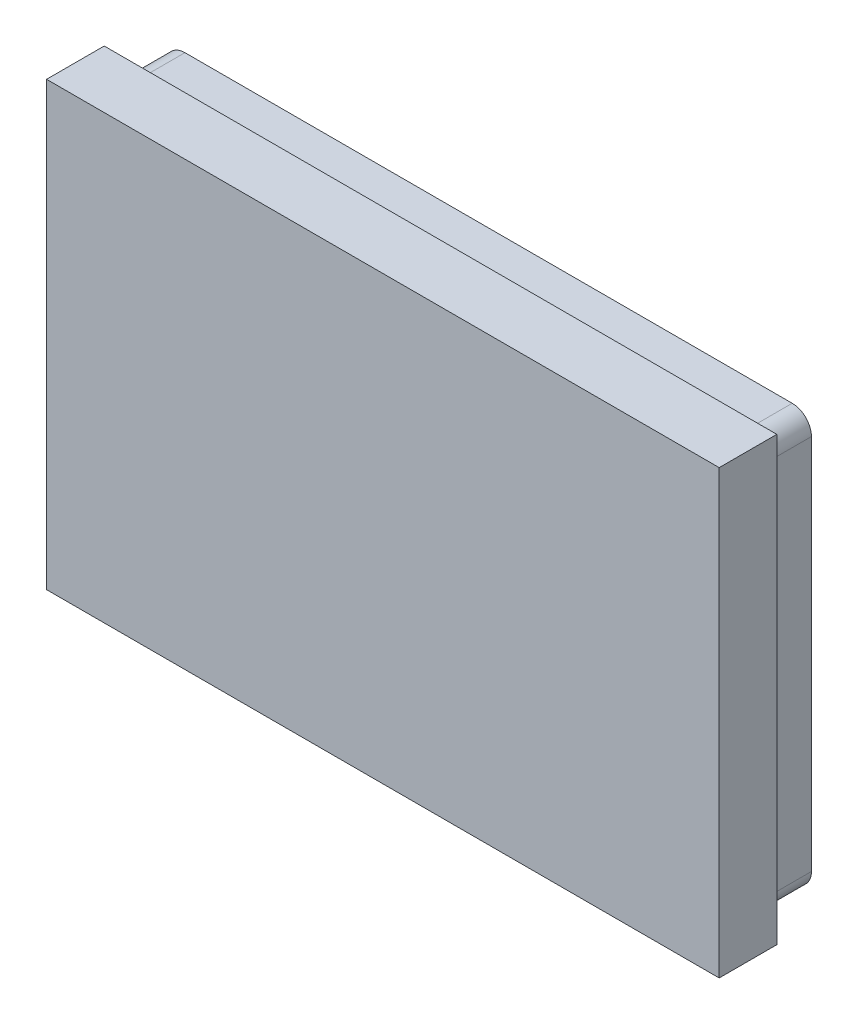
from build123d import *

# Parameters (mm, degrees)
ESQUISSE3_W        = 35
ESQUISSE3_H        = 23
BOSS_EXTRU_1_DEPTH = 3
BOSS_EXTRU_2_DEPTH = 2.5
BOSS_EXTRU_3_DEPTH = 2.5
BOSS_EXTRU_4_DEPTH = 2.5


with BuildPart() as part:
    # Esquisse3 → Boss.-Extru.1 (new body)
    with BuildSketch(Plane.XY):
        with Locations((17.5, 11.5)):
            Rectangle(ESQUISSE3_W, ESQUISSE3_H)
    extrude(amount=BOSS_EXTRU_1_DEPTH)

    # Esquisse4 → Boss.-Extru.2 (add)
    with BuildSketch(Plane(origin=(0, 0, 0), x_dir=(-1, 0, 0), z_dir=(0, 0, -1))):
        with BuildLine():
            Line((-33.3, 22.3), (-1.7, 22.3))
            ThreePointArc((-1.7, 22.3), (-0.992893219, 22.007106781), (-0.7, 21.3))
            Line((-0.7, 21.3), (-0.7, 1.7))
            ThreePointArc((-0.7, 1.7), (-0.992893219, 0.992893219), (-1.7, 0.7))
            Line((-1.7, 0.7), (-33.3, 0.7))
            ThreePointArc((-33.3, 0.7), (-34.007106781, 0.992893219), (-34.3, 1.7))
            Line((-34.3, 1.7), (-34.3, 21.3))
            ThreePointArc((-34.3, 21.3), (-34.007106781, 22.007106781), (-33.3, 22.3))
        make_face()
        with BuildLine():
            Line((-33, 21.7), (-2, 21.7))
            ThreePointArc((-2, 21.7), (-1.505025253, 21.494974747), (-1.3, 21))
            Line((-1.3, 21), (-1.3, 2))
            ThreePointArc((-1.3, 2), (-1.505025253, 1.505025253), (-2, 1.3))
            Line((-2, 1.3), (-33, 1.3))
            ThreePointArc((-33, 1.3), (-33.494974747, 1.505025253), (-33.7, 2))
            Line((-33.7, 2), (-33.7, 21))
            ThreePointArc((-33.7, 21), (-33.494974747, 21.494974747), (-33, 21.7))
        make_face(mode=Mode.SUBTRACT)
    extrude(amount=BOSS_EXTRU_2_DEPTH)

    # Esquisse5 → Boss.-Extru.3 (add)
    with BuildSketch(Plane(origin=(0, 0, 0), x_dir=(-1, 0, 0), z_dir=(0, 0, -1))):
        Polygon((-6.584721452, 15.316649388), (-5.479648989, 15.316649388), (-4.988254061, 16.909720041), (-4.809359134, 17.558497214), (-4.621406235, 16.893868591), (-4.092647177, 15.316649388), (-3.033996815, 15.316649388), (-2.780373626, 20.316649388), (-3.610310221, 20.316649388), (-3.707683409, 17.111259896), (-3.732592829, 16.2349012), (-3.9760258, 16.988977287), (-4.569322902, 18.794910258), (-5.161487757, 18.794910258), (-5.740065655, 16.854239968), (-5.926886308, 16.242826925), (-5.939341018, 17.022944678), (-6.040110945, 20.316649388), (-6.838344641, 20.316649388), align=None)
        Polygon((-7.671677974, 15.316649388), (-7.671677974, 20.316649388), (-10.715156235, 20.316649388), (-10.715156235, 19.519547939), (-8.61370696, 19.519547939), (-8.61370696, 18.287663881), (-10.642692467, 18.287663881), (-10.642692467, 17.490562432), (-8.61370696, 17.490562432), (-8.61370696, 16.113750838), (-10.715156235, 16.113750838), (-10.715156235, 15.316649388), align=None)
        Polygon((-18.83562725, 15.316649388), (-18.740518554, 18.15066207), (-18.70428667, 19.2817762), (-18.45745696, 18.560535258), (-17.887937032, 16.838388519), (-17.299168916, 16.838388519), (-16.80437725, 18.560535258), (-16.597176163, 19.2817762), (-16.567737757, 18.173306997), (-16.477158047, 15.316649388), (-15.678924351, 15.316649388), (-15.932547539, 20.316649388), (-16.994594641, 20.316649388), (-17.428245003, 18.876431997), (-17.63544609, 18.064611345), (-17.852837394, 18.830009896), (-18.329513119, 20.316649388), (-19.410808409, 20.316649388), (-19.664431597, 15.316649388), align=None)
        Polygon((-22.97285551, 15.316649388), (-22.694322902, 16.331142142), (-20.954060221, 16.331142142), (-20.668734134, 15.316649388), (-19.736895366, 15.316649388), (-21.220138119, 20.316649388), (-22.534676163, 20.316649388), (-24.012257684, 15.316649388), align=None)
        Polygon((-21.838344641, 19.459538881), (-21.180509496, 17.128243591), (-22.476931597, 17.128243591), align=None, mode=Mode.SUBTRACT)
        Polygon((-27.019504061, 15.316649388), (-25.497764931, 17.733995403), (-25.497764931, 15.316649388), (-24.555735945, 15.316649388), (-24.555735945, 20.316649388), (-25.497764931, 20.316649388), (-25.497764931, 17.995544316), (-27.044413481, 20.316649388), (-28.178924351, 20.316649388), (-26.430735945, 17.915154823), (-28.234404423, 15.316649388), align=None)
        Polygon((-29.048489568, 15.316649388), (-29.048489568, 20.316649388), (-32.091967829, 20.316649388), (-32.091967829, 19.519547939), (-29.990518554, 19.519547939), (-29.990518554, 18.287663881), (-32.019504061, 18.287663881), (-32.019504061, 17.490562432), (-29.990518554, 17.490562432), (-29.990518554, 16.113750838), (-32.091967829, 16.113750838), (-32.091967829, 15.316649388), align=None)
    extrude(amount=BOSS_EXTRU_3_DEPTH)

    # Esquisse7 → Boss.-Extru.4 (add)
    with BuildSketch(Plane(origin=(0, 0, 0), x_dir=(-1, 0, 0), z_dir=(0, 0, -1))):
        with BuildLine():
            add(Edge.make_bspline(
                [(-8.817747763, 9.314224142), (-8.814780119, 9.205506733), (-8.808942438, 8.991647656), (-8.762927378, 8.677420866), (-8.690845179, 8.375371259), (-8.58588107, 8.087519577), (-8.453474945, 7.814742721), (-8.289699633, 7.56056938), (-8.098821055, 7.324302512), (-7.877184803, 7.109473557), (-7.627410891, 6.915701806), (-7.347369711, 6.746245514), (-7.039802704, 6.597385002), (-6.70353827, 6.47307545), (-6.339922496, 6.371040526), (-5.947059319, 6.30536668), (-5.527582272, 6.257959268), (-5.238170675, 6.254172069), (-5.089001447, 6.252220061)],
                knots=[0, 0, 0, 0, 0.000326028, 0.000641332, 0.000950735, 0.001256132, 0.001558628, 0.001858505, 0.002161265, 0.002467876, 0.002782402, 0.003107603, 0.003448034, 0.003805964, 0.004181842, 0.004579127, 0.004999629, 0.005446896, 0.005446896, 0.005446896, 0.005446896], degree=3))
            Line((-5.089001447, 6.252220061), (-4.214143138, 6.252220061))
            Line((-4.214143138, 6.252220061), (-4.214143138, 3.519733097))
            Line((-4.214143138, 3.519733097), (-2.481769526, 3.519733097))
            Line((-2.481769526, 3.519733097), (-2.481769526, 12.019733097))
            Line((-2.481769526, 12.019733097), (-5.158373471, 12.019733097))
            add(Edge.make_bspline(
                [(-5.158373471, 12.019733097), (-5.301678682, 12.01747456), (-5.580327474, 12.013082963), (-5.985818438, 11.980271354), (-6.365985176, 11.925810589), (-6.71965664, 11.845630839), (-7.0488036, 11.749471573), (-7.349709983, 11.627715027), (-7.624270715, 11.486399568), (-7.872366824, 11.325250737), (-8.091346919, 11.140475141), (-8.283906388, 10.937686688), (-8.44742762, 10.713425051), (-8.582248531, 10.469927813), (-8.689602869, 10.207632387), (-8.764238727, 9.925937057), (-8.808902863, 9.62590226), (-8.814753892, 9.419722686), (-8.817747763, 9.314224142)],
                knots=[0, 0, 0, 0, 0.000429877, 0.000835871, 0.001219581, 0.001580964, 0.001922978, 0.002247179, 0.002553141, 0.002848167, 0.003132647, 0.003410736, 0.003685163, 0.003962919, 0.004243825, 0.00453317, 0.004835126, 0.00515153, 0.00515153, 0.00515153, 0.00515153], degree=3))
        make_face()
        with BuildLine():
            add(Edge.make_bspline(
                [(-7.016002127, 9.204385103), (-7.014435945, 9.259690989), (-7.011382707, 9.367508671), (-6.989960867, 9.525799552), (-6.953383113, 9.675475656), (-6.903332905, 9.818012799), (-6.837430434, 9.950917504), (-6.758079256, 10.075580637), (-6.663423931, 10.190105607), (-6.551987026, 10.291923723), (-6.42800876, 10.386310201), (-6.28665871, 10.46592213), (-6.130858503, 10.536414431), (-5.958863362, 10.593234882), (-5.771532984, 10.639800715), (-5.567826504, 10.671957108), (-5.34760432, 10.691383553), (-5.195029299, 10.69307848), (-5.115979456, 10.693956629)],
                knots=[0, 0, 0, 0, 0.000165901, 0.000323421, 0.000478122, 0.000627449, 0.000775678, 0.000922143, 0.001069932, 0.001219917, 0.001374077, 0.001536369, 0.001705419, 0.001886403, 0.002078958, 0.002283928, 0.00250445, 0.002741541, 0.002741541, 0.002741541, 0.002741541], degree=3))
            Line((-5.115979456, 10.693956629), (-4.214143138, 10.693956629))
            Line((-4.214143138, 10.693956629), (-4.214143138, 7.577996529))
            Line((-4.214143138, 7.577996529), (-5.171862476, 7.577996529))
            add(Edge.make_bspline(
                [(-5.171862476, 7.577996529), (-5.244506876, 7.579483738), (-5.384979631, 7.58235956), (-5.58910513, 7.604284199), (-5.780263267, 7.637724065), (-5.958288586, 7.687990995), (-6.122816971, 7.752500231), (-6.275870951, 7.826136733), (-6.413257292, 7.916184934), (-6.538324753, 8.016515748), (-6.647668785, 8.130894108), (-6.744536776, 8.254796664), (-6.828792656, 8.388421912), (-6.89535982, 8.534098658), (-6.950122838, 8.688643616), (-6.987943508, 8.852849454), (-7.011898418, 9.025751459), (-7.014613164, 9.143923805), (-7.016002127, 9.204385103)],
                knots=[0, 0, 0, 0, 0.000217887, 0.00042133, 0.000615231, 0.000799458, 0.000975164, 0.001144937, 0.00130796, 0.001466864, 0.001624949, 0.001781452, 0.001938121, 0.002097608, 0.002260938, 0.002429206, 0.002602261, 0.002783563, 0.002783563, 0.002783563, 0.002783563], degree=3))
        make_face(mode=Mode.SUBTRACT)
        with BuildLine():
            add(Edge.make_bspline(
                [(-17.040259665, 7.80538261), (-17.037584538, 7.618935783), (-17.032414822, 7.258625051), (-16.974385002, 6.738245696), (-16.886724091, 6.256581468), (-16.758540243, 5.815178867), (-16.600643458, 5.412817311), (-16.415096781, 5.046831071), (-16.201349174, 4.718477923), (-15.961086606, 4.426593959), (-15.695039437, 4.172809855), (-15.407169257, 3.953463691), (-15.095708585, 3.771811546), (-14.765753922, 3.622906205), (-14.418865664, 3.510359585), (-14.059526482, 3.429647053), (-13.688837718, 3.377004353), (-13.436948079, 3.371971687), (-13.309586348, 3.369427044)],
                knots=[0, 0, 0, 0, 0.000559099, 0.001080466, 0.001568762, 0.002026156, 0.002456995, 0.00286377, 0.003255008, 0.003630036, 0.003995303, 0.004355657, 0.00471325, 0.005074633, 0.005439651, 0.005805218, 0.006178579, 0.006560436, 0.006560436, 0.006560436, 0.006560436], degree=3))
            add(Edge.make_bspline(
                [(-13.309586348, 3.369427044), (-13.16360512, 3.372521153), (-12.880295652, 3.378525969), (-12.469962605, 3.431557732), (-12.086980341, 3.51670416), (-11.732900306, 3.641527061), (-11.403737887, 3.796399293), (-11.105667052, 3.991941182), (-10.832443595, 4.218084273), (-10.591171362, 4.482573821), (-10.378923985, 4.779776843), (-10.192634174, 5.107431906), (-10.037116766, 5.467679138), (-9.910429596, 5.859597989), (-9.810505499, 6.282314671), (-9.740424964, 6.736537172), (-9.697345634, 7.221946946), (-9.692946735, 7.556063242), (-9.690679071, 7.728302582)],
                knots=[0, 0, 0, 0, 0.000437773, 0.000849597, 0.001238994, 0.001612579, 0.001973715, 0.00232755, 0.002679136, 0.003035089, 0.00339821, 0.003772748, 0.004163682, 0.004573187, 0.005006933, 0.005465357, 0.005950888, 0.006467501, 0.006467501, 0.006467501, 0.006467501], degree=3))
            add(Edge.make_bspline(
                [(-9.690679071, 7.728302582), (-9.693305502, 7.914757071), (-9.698381111, 8.27508261), (-9.756982328, 8.794613096), (-9.842188292, 9.275903593), (-9.969898581, 9.717106095), (-10.131366906, 10.118809705), (-10.314540856, 10.48630835), (-10.530318808, 10.813465079), (-10.769765156, 11.105202623), (-11.035878268, 11.359013281), (-11.32349403, 11.577666652), (-11.633615092, 11.760511795), (-11.963317842, 11.908727359), (-12.310699206, 12.021749858), (-12.670832876, 12.101845921), (-13.042090109, 12.15479955), (-13.293986994, 12.159801856), (-13.421352388, 12.162331147)],
                knots=[0, 0, 0, 0, 0.000559099, 0.001080466, 0.001566513, 0.002023907, 0.002455457, 0.002863949, 0.003253575, 0.003628603, 0.00399387, 0.004354224, 0.004710157, 0.00507154, 0.005436558, 0.005804004, 0.006177365, 0.006559222, 0.006559222, 0.006559222, 0.006559222], degree=3))
            add(Edge.make_bspline(
                [(-13.421352388, 12.162331147), (-13.567327295, 12.159219208), (-13.850624495, 12.15317979), (-14.261043809, 12.100391365), (-14.643517814, 12.014437932), (-14.998469166, 11.892711215), (-15.327047013, 11.737012096), (-15.625233583, 11.542478013), (-15.896046342, 11.314976981), (-16.138348599, 11.052476929), (-16.352229181, 10.756404128), (-16.537686793, 10.428532687), (-16.694326611, 10.069443944), (-16.820397733, 9.677896263), (-16.920682307, 9.254630946), (-16.990461028, 8.799054665), (-17.033546647, 8.312378557), (-17.037979082, 7.977622048), (-17.040259665, 7.80538261)],
                knots=[0, 0, 0, 0, 0.000437773, 0.000849597, 0.001238994, 0.001611947, 0.001973084, 0.002326918, 0.002677028, 0.003031565, 0.003395814, 0.003770351, 0.00415952, 0.004569024, 0.005002771, 0.005463098, 0.005950549, 0.006467162, 0.006467162, 0.006467162, 0.006467162], degree=3))
        make_face()
        with BuildLine():
            add(Edge.make_bspline(
                [(-15.223098023, 7.728302582), (-15.221315644, 7.850361154), (-15.217870558, 8.08628302), (-15.200096505, 8.427923105), (-15.164262832, 8.744714325), (-15.119879264, 9.038582185), (-15.058535123, 9.308435145), (-14.982866981, 9.554102499), (-14.897917442, 9.777310698), (-14.795099563, 9.975764267), (-14.6772946, 10.150894816), (-14.542653832, 10.303988807), (-14.390059048, 10.434132862), (-14.217941569, 10.538923627), (-14.029128736, 10.620368929), (-13.823009152, 10.677690957), (-13.599847551, 10.712952296), (-13.445254587, 10.716946325), (-13.365469368, 10.719007638)],
                knots=[0, 0, 0, 0, 0.000366211, 0.000707834, 0.00102576, 0.001322293, 0.001599031, 0.001855039, 0.002093006, 0.002314511, 0.002524023, 0.002724699, 0.002924309, 0.003123267, 0.003326955, 0.00353924, 0.003763544, 0.004002771, 0.004002771, 0.004002771, 0.004002771], degree=3))
            add(Edge.make_bspline(
                [(-13.365469368, 10.719007638), (-13.285648632, 10.717178397), (-13.131519019, 10.713646229), (-12.909789818, 10.675508973), (-12.704968321, 10.6170503), (-12.519060446, 10.530758441), (-12.348803373, 10.424586885), (-12.197111225, 10.292579499), (-12.059352697, 10.139584616), (-11.938156509, 9.962812375), (-11.832592343, 9.765369236), (-11.740887432, 9.546896578), (-11.667227578, 9.306469078), (-11.608133997, 9.044790543), (-11.56144463, 8.763666101), (-11.533230785, 8.461609273), (-11.509608832, 8.140403708), (-11.508441009, 7.919126), (-11.507840712, 7.80538261)],
                knots=[0, 0, 0, 0, 0.000239228, 0.000461936, 0.000672905, 0.000876402, 0.001074743, 0.001272887, 0.001477567, 0.001690847, 0.001914154, 0.002148212, 0.002400538, 0.002667454, 0.002952572, 0.003254761, 0.003577267, 0.003918396, 0.003918396, 0.003918396, 0.003918396], degree=3))
            add(Edge.make_bspline(
                [(-11.507840712, 7.80538261), (-11.509597052, 7.683319645), (-11.512991807, 7.447389289), (-11.531115855, 7.105808245), (-11.565764736, 6.788713618), (-11.614176874, 6.495564476), (-11.672232161, 6.224497425), (-11.747282914, 5.977735708), (-11.83537565, 5.754864704), (-11.937713784, 5.556005478), (-12.055551321, 5.380290091), (-12.191561595, 5.228275846), (-12.345321171, 5.099648044), (-12.516776993, 4.994639376), (-12.705155037, 4.913737727), (-12.910401597, 4.855669564), (-13.132400519, 4.82089747), (-13.286334725, 4.816789423), (-13.365469368, 4.814677554)],
                knots=[0, 0, 0, 0, 0.000366211, 0.000707834, 0.00102576, 0.0013226, 0.001598914, 0.001856765, 0.002095441, 0.002316946, 0.002526458, 0.002728416, 0.002926785, 0.003125743, 0.003329431, 0.003539863, 0.003764166, 0.004001469, 0.004001469, 0.004001469, 0.004001469], degree=3))
            add(Edge.make_bspline(
                [(-13.365469368, 4.814677554), (-13.445272133, 4.816575966), (-13.60000119, 4.820256784), (-13.82258944, 4.857698132), (-14.027253925, 4.917347716), (-14.215011639, 5.000104458), (-14.383509107, 5.110163376), (-14.537744738, 5.240226621), (-14.674772664, 5.393530589), (-14.795357985, 5.569267452), (-14.898304102, 5.76742949), (-14.989882136, 5.98537644), (-15.06150638, 6.226209112), (-15.121145686, 6.486913365), (-15.167053587, 6.768863472), (-15.198327951, 7.071298328), (-15.221146298, 7.393301453), (-15.222435391, 7.614565972), (-15.223098023, 7.728302582)],
                knots=[0, 0, 0, 0, 0.000239228, 0.000463837, 0.000674806, 0.000877508, 0.001076885, 0.001276495, 0.001481174, 0.001691774, 0.001914173, 0.002150009, 0.002399925, 0.002666841, 0.002951959, 0.003256266, 0.003578773, 0.003919901, 0.003919901, 0.003919901, 0.003919901], degree=3))
        make_face(mode=Mode.SUBTRACT)
        with BuildLine():
            Line((-22.830896709, 3.519733097), (-21.545587255, 6.252220061))
            add(Edge.make_bspline(
                [(-21.545587255, 6.252220061), (-21.513934265, 6.314277417), (-21.452411052, 6.434896919), (-21.33254639, 6.595350636), (-21.194574264, 6.731466314), (-21.039463401, 6.844203994), (-20.868286444, 6.931583366), (-20.682374541, 6.992872768), (-20.482982651, 7.03329977), (-20.344628898, 7.036696566), (-20.273766806, 7.038436339)],
                knots=[0, 0, 0, 0, 0.000208695, 0.000405636, 0.000597767, 0.00078818, 0.000978641, 0.001171813, 0.001374001, 0.001586286, 0.001586286, 0.001586286, 0.001586286], degree=3))
            Line((-20.273766806, 7.038436339), (-19.94424969, 7.038436339))
            Line((-19.94424969, 7.038436339), (-19.94424969, 3.519733097))
            Line((-19.94424969, 3.519733097), (-18.227292084, 3.519733097))
            Line((-18.227292084, 3.519733097), (-18.227292084, 12.019733097))
            Line((-18.227292084, 12.019733097), (-20.888480023, 12.019733097))
            add(Edge.make_bspline(
                [(-20.888480023, 12.019733097), (-21.011212101, 12.018393777), (-21.251121308, 12.015775756), (-21.602060889, 11.991266783), (-21.936261907, 11.956706017), (-22.2519361, 11.901833561), (-22.549391217, 11.835220218), (-22.82397996, 11.744070893), (-23.075972357, 11.634463613), (-23.305479351, 11.505176254), (-23.511280403, 11.354531412), (-23.692235991, 11.181695166), (-23.847534206, 10.987169578), (-23.978320677, 10.771333007), (-24.080493295, 10.531239484), (-24.156705614, 10.267613332), (-24.197492797, 9.977733746), (-24.203605619, 9.776821708), (-24.206775194, 9.672646269)],
                knots=[0, 0, 0, 0, 0.000368138, 0.000719613, 0.001054989, 0.00137559, 0.001680349, 0.001968582, 0.002242114, 0.002503598, 0.002757202, 0.003005254, 0.00325203, 0.003501872, 0.003759961, 0.004032596, 0.004322832, 0.004635386, 0.004635386, 0.004635386, 0.004635386], degree=3))
            add(Edge.make_bspline(
                [(-24.206775194, 9.672646269), (-24.204865831, 9.596769673), (-24.201147766, 9.449016659), (-24.173935733, 9.233424062), (-24.128385117, 9.030424984), (-24.062263075, 8.840994017), (-23.980294595, 8.664946024), (-23.886914648, 8.499181451), (-23.773275226, 8.349220437), (-23.648551303, 8.209445111), (-23.508328728, 8.084631493), (-23.357623403, 7.969024596), (-23.191483435, 7.869694185), (-23.013606453, 7.783579536), (-22.827159423, 7.707893393), (-22.630696758, 7.647322234), (-22.427318611, 7.593676949), (-22.287073073, 7.570461288), (-22.216183492, 7.558726522)],
                knots=[0, 0, 0, 0, 0.00022759, 0.000443182, 0.000650735, 0.000850624, 0.001043757, 0.001232819, 0.001420125, 0.001607044, 0.001793963, 0.001982425, 0.002176087, 0.002373442, 0.002574903, 0.002779066, 0.00298985, 0.003205295, 0.003205295, 0.003205295, 0.003205295], degree=3))
            add(Edge.make_bspline(
                [(-22.216183492, 7.558726522), (-22.271448896, 7.545254307), (-22.383530679, 7.517931791), (-22.54205523, 7.439613282), (-22.694603095, 7.336708666), (-22.837659294, 7.201634671), (-22.979875483, 7.040384493), (-23.117320234, 6.844818009), (-23.25892289, 6.620075651), (-23.344724008, 6.454621311), (-23.389726906, 6.367840102)],
                knots=[0, 0, 0, 0, 0.000170199, 0.000345174, 0.000526896, 0.000720557, 0.000933558, 0.00117101, 0.001436754, 0.001729886, 0.001729886, 0.001729886, 0.001729886], degree=3))
            Line((-23.389726906, 6.367840102), (-24.848466421, 3.519733097))
            Line((-24.848466421, 3.519733097), (-22.830896709, 3.519733097))
        make_face()
        with BuildLine():
            add(Edge.make_bspline(
                [(-22.403102558, 9.516559213), (-22.402414452, 9.566755684), (-22.401075562, 9.664426156), (-22.378750236, 9.80437032), (-22.346608527, 9.933981262), (-22.299824896, 10.052405416), (-22.240967686, 10.160998894), (-22.165636657, 10.256747628), (-22.078750009, 10.342380951), (-21.976859885, 10.415951993), (-21.862287514, 10.478853263), (-21.735534414, 10.535597202), (-21.595506716, 10.582965534), (-21.441577183, 10.621953183), (-21.274493114, 10.649554103), (-21.094450247, 10.670666468), (-20.901548704, 10.684749509), (-20.768389552, 10.68573815), (-20.699633956, 10.686248626)],
                knots=[0, 0, 0, 0, 0.000150417, 0.000292676, 0.00042401, 0.000550327, 0.00067367, 0.00079316, 0.000914439, 0.001038547, 0.001168816, 0.001305972, 0.001454663, 0.001611699, 0.001781822, 0.001962282, 0.002155453, 0.002361679, 0.002361679, 0.002361679, 0.002361679], degree=3))
            Line((-20.699633956, 10.686248626), (-19.94424969, 10.686248626))
            Line((-19.94424969, 10.686248626), (-19.94424969, 8.28713278))
            Line((-19.94424969, 8.28713278), (-20.643750937, 8.28713278))
            add(Edge.make_bspline(
                [(-20.643750937, 8.28713278), (-20.770490313, 8.290574707), (-21.013211192, 8.297166404), (-21.307347007, 8.345343902), (-21.52102627, 8.406182415), (-21.666787836, 8.458579915), (-21.799812547, 8.523676449), (-21.921397365, 8.596629298), (-22.032019709, 8.678474218), (-22.126480665, 8.772897035), (-22.211389535, 8.873329537), (-22.280351175, 8.985184937), (-22.334637812, 9.106517172), (-22.375714599, 9.235540133), (-22.398777841, 9.373779187), (-22.401640877, 9.468302014), (-22.403102558, 9.516559213)],
                knots=[0, 0, 0, 0, 0.000380108, 0.000727952, 0.000890209, 0.001046284, 0.001191935, 0.001333711, 0.001471299, 0.001603478, 0.001733504, 0.001865049, 0.001996142, 0.002131444, 0.002270202, 0.002414932, 0.002414932, 0.002414932, 0.002414932], degree=3))
        make_face(mode=Mode.SUBTRACT)
        Polygon((-30.388593376, 3.519733097), (-27.943229513, 8.593525888), (-27.440282335, 9.686135273), (-27.440282335, 6.159724029), (-27.440282335, 3.519733097), (-25.875557783, 3.519733097), (-25.875557783, 12.019733097), (-27.985623528, 12.019733097), (-30.479162408, 6.915108295), (-30.918518563, 5.918848944), (-30.918518563, 9.672646269), (-30.918518563, 12.019733097), (-32.483243115, 12.019733097), (-32.483243115, 3.519733097), align=None)
    extrude(amount=BOSS_EXTRU_4_DEPTH)


solid = part.part
